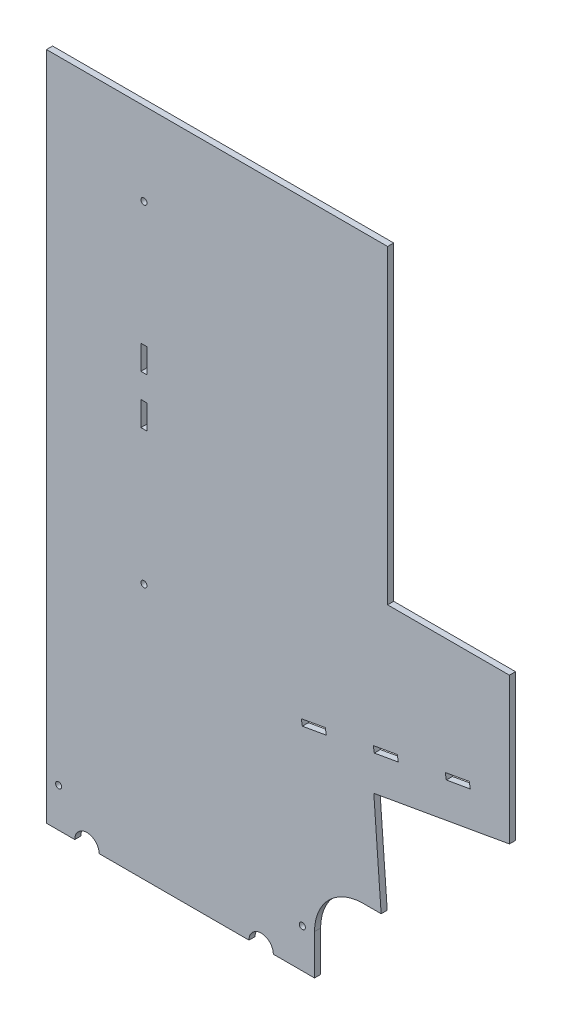
from build123d import *

# Parameters (mm, degrees)
BOSS_EXTRUDE1_DEPTH = 3.175
SKETCH2_R           = 1.5875
CUT_EXTRUDE1_DEPTH  = 3.175
BOSS_EXTRUDE2_DEPTH = 3.175
CUT_EXTRUDE2_DEPTH  = 3.175
SKETCH5_W           = 1.5875
SKETCH5_H           = 12.7
CUT_EXTRUDE3_DEPTH  = 10.16
LPATTERN1_COUNT     = 2
LPATTERN1_PITCH     = 25.4
SKETCH8_W           = 38.1
SKETCH8_H           = 46.355
CUT_EXTRUDE6_DEPTH  = 12.7
SKETCH10_R          = 1.5875
CUT_EXTRUDE7_DEPTH  = 7.62
SKETCH11_R          = 6.35
CUT_EXTRUDE8_DEPTH  = 12.7
FILLET1_R           = 25.4
SKETCH13_W          = 25.4
SKETCH13_H          = 177.8
BOSS_EXTRUDE3_DEPTH = 3.175
LPATTERN2_COUNT     = 2
LPATTERN2_PITCH     = 76.2


with BuildPart() as part:
    # Sketch1 → Boss-Extrude1 (new body)
    with BuildSketch(Plane.XY):
        Polygon((0, 0), (-177.8, 0), (-177.8, 349.25), (-25.4, 349.25), align=None)
    extrude(amount=BOSS_EXTRUDE1_DEPTH)

    # Sketch2 → Cut-Extrude1 (cut)
    with BuildSketch(Plane.XY.offset(3.175)):
        with Locations((-127, 133.35)):
            Circle(SKETCH2_R)
        with Locations((-127, 306.07)):
            Circle(SKETCH2_R)
    extrude(amount=-CUT_EXTRUDE1_DEPTH, mode=Mode.SUBTRACT)

    # Sketch3 → Boss-Extrude2 (add)
    with BuildSketch(Plane.XY.offset(3.175)):
        Polygon((-63.5, 88.9), (63.5, 111.29352655), (63.5, 187.49352655), (-63.5, 187.49352655), align=None)
    extrude(amount=-BOSS_EXTRUDE2_DEPTH)

    # Sketch4 → Cut-Extrude2 (cut)
    with BuildSketch(Plane.XY.offset(3.175)):
        Polygon((-44.45, 110.49), (-31.942941537, 112.695331856), (-32.494274501, 115.822096472), (-45.001332964, 113.616764616), align=None)
        Polygon((-6.92882461, 117.105995569), (5.578233853, 119.311327425), (5.026900889, 122.438092041), (-7.480157574, 120.232760185), align=None)
    cut_extrude2 = extrude(amount=-CUT_EXTRUDE2_DEPTH, mode=Mode.SUBTRACT)

    # Sketch5 → Cut-Extrude3 (cut)
    with BuildSketch(Plane.XY.offset(3.175)):
        with Locations((-126.20625, 209.55)):
            Rectangle(SKETCH5_W, SKETCH5_H)
        with Locations((-127.79375, 209.55)):
            Rectangle(SKETCH5_W, SKETCH5_H)
    cut_extrude3 = extrude(amount=-CUT_EXTRUDE3_DEPTH, mode=Mode.SUBTRACT)

    # LPattern1: Cut-Extrude3 ×2
    with Locations(*[(0, i * LPATTERN1_PITCH, 0) for i in range(1, LPATTERN1_COUNT)]):
        add(cut_extrude3, mode=Mode.SUBTRACT)

    # Sketch8 → Cut-Extrude6 (cut)
    with BuildSketch(Plane.XY.offset(3.175)):
        with Locations((-19.05, 23.1775)):
            Rectangle(SKETCH8_W, SKETCH8_H)
    extrude(amount=-CUT_EXTRUDE6_DEPTH, mode=Mode.SUBTRACT)

    # Sketch10 → Cut-Extrude7 (cut)
    with BuildSketch(Plane(origin=(0, 0, 0), x_dir=(-1, 0, 0), z_dir=(0, 0, -1))):
        with Locations((171.45, 20.32)):
            Circle(SKETCH10_R)
        with Locations((44.45, 20.32)):
            Circle(SKETCH10_R)
    extrude(amount=-CUT_EXTRUDE7_DEPTH, mode=Mode.SUBTRACT)

    # Sketch11 → Cut-Extrude8 (cut)
    with BuildSketch(Plane(origin=(0, 0, 0), x_dir=(-1, 0, 0), z_dir=(0, 0, -1))):
        with Locations((156.718, 0)):
            Circle(SKETCH11_R)
        with Locations((65.913, 0)):
            Circle(SKETCH11_R)
    extrude(amount=-CUT_EXTRUDE8_DEPTH, mode=Mode.SUBTRACT)

    # Fillet1
    fillet1_edges = [part.edges().sort_by_distance(p)[0] for p in [
        (-38.1, 46.355, 1.5875),
    ]]
    fillet(fillet1_edges, radius=FILLET1_R)

    # Sketch13 → Boss-Extrude3 (add)
    with BuildSketch(Plane(origin=(0, 0, 0), x_dir=(-1, 0, 0), z_dir=(0, 0, -1))):
        with Locations((12.7, 260.35)):
            Rectangle(SKETCH13_W, SKETCH13_H)
    extrude(amount=-BOSS_EXTRUDE3_DEPTH)

    # LPattern2: Cut-Extrude2 ×2
    with Locations(*[Vector(0.984807753, 0.173648178, 0) * (i * LPATTERN2_PITCH) for i in range(1, LPATTERN2_COUNT)]):
        add(cut_extrude2, mode=Mode.SUBTRACT)


solid = part.part
